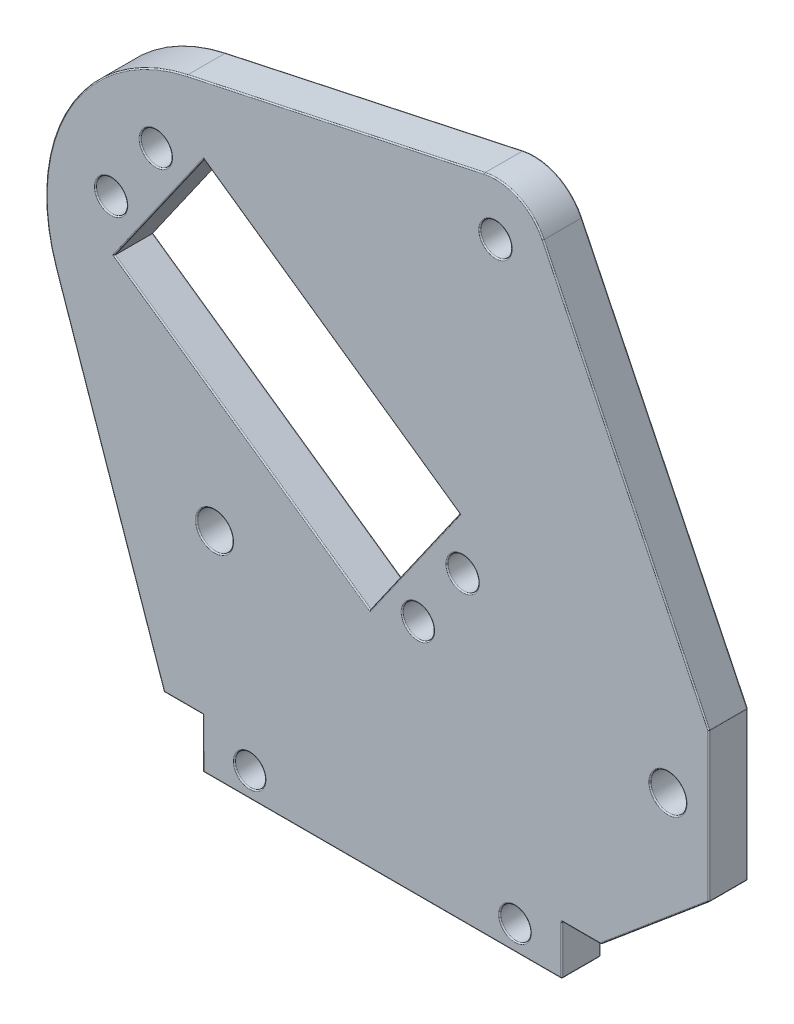
from build123d import *

# Parameters (mm, degrees)
SKETCH2_R           = 2
SKETCH2_R_2         = 2.3
SKETCH2_R_3         = 1.95
BOSS_EXTRUDE2_DEPTH = 5
SKETCH4_W           = 46
SKETCH4_H           = 3.65
CUT_EXTRUDE1_DEPTH  = 6
FILLET1_R           = 0.15


with BuildPart() as part:
    # Sketch2 → Boss-Extrude2 (new body)
    with BuildSketch(Plane.XY):
        with BuildLine():
            Line((-23, 0), (-23, 10))
            Line((-23, 10), (-28, 10))
            Line((-28, 10), (-41.843761624, 50.118193368))
            ThreePointArc((-41.843761624, 50.118193368), (-40.146654928, 68.813612437), (-25.029728066, 79.943634341))
            Line((-25.029728066, 79.943634341), (13.072325527, 88.138211024))
            ThreePointArc((13.072325527, 88.138211024), (17.477220077, 87.602479874), (20.610605748, 84.460506273))
            Line((20.610605748, 84.460506273), (41.85, 40.621529892))
            Line((41.85, 40.621529892), (41.85, 21.621529892))
            Line((41.85, 21.621529892), (28, 10))
            Line((28, 10), (23, 10))
            Line((23, 10), (23, 0))
            Line((23, 0), (-23, 0))
        make_face()
        with Locations((-29.025034449, 69.849224439)):
            Circle(SKETCH2_R, mode=Mode.SUBTRACT)
        with Locations((-34.760798813, 61.657703997)):
            Circle(SKETCH2_R, mode=Mode.SUBTRACT)
        with Locations((10.294263677, 42.317555495)):
            Circle(SKETCH2_R, mode=Mode.SUBTRACT)
        with Locations((4.558499313, 34.126035052)):
            Circle(SKETCH2_R, mode=Mode.SUBTRACT)
        with Locations((14.5, 81.5)):
            Circle(SKETCH2_R, mode=Mode.SUBTRACT)
        with Locations((36.6, 31.121529892)):
            Circle(SKETCH2_R_2, mode=Mode.SUBTRACT)
        with Locations((17, 6.8)):
            Circle(SKETCH2_R_3, mode=Mode.SUBTRACT)
        with Locations((-17, 6.8)):
            Circle(SKETCH2_R_3, mode=Mode.SUBTRACT)
        with Locations((-21.5, 31.121529892)):
            Circle(SKETCH2_R_2, mode=Mode.SUBTRACT)
        Polygon((-22.88054409, 71.650678915), (-34.352072817, 55.26763803), (-1.585991046, 32.324580576), (9.885537681, 48.707621461), align=None, mode=Mode.SUBTRACT)
    extrude(amount=-BOSS_EXTRUDE2_DEPTH)

    # Sketch4 → Cut-Extrude1 (cut, through all)
    with BuildSketch(Plane.XY):
        with Locations((0, 1.825)):
            Rectangle(SKETCH4_W, SKETCH4_H)
    extrude(amount=-CUT_EXTRUDE1_DEPTH, mode=Mode.SUBTRACT)

    # Fillet1
    fillet1_edges = [part.edges().sort_by_distance(p)[0] for p in [
        (-23, 6.825, 0),
        (-25.5, 10, 0),
        (25.5, 10, -5),
        (-34.921880812, 30.059096684, 0),
        (-40.146654928, 68.813612437, 0),
        (-5.978701269, 84.040922682, 0),
        (17.477220077, 87.602479874, 0),
        (31.230302874, 62.541018083, 0),
        (41.85, 31.121529892, 0),
        (34.925, 15.810764946, 0),
        (25.5, 10, 0),
        (34.925, 15.810764946, -5),
        (-28, 10, -2.5),
        (41.85, 31.121529892, -5),
        (41.85, 40.621529892, -2.5),
        (41.85, 21.621529892, -2.5),
        (28, 10, -2.5),
        (23, 10, -2.5),
        (31.230302874, 62.541018083, -5),
        (17.477220077, 87.602479874, -5),
        (-5.978701269, 84.040922682, -5),
        (-6.497503205, 60.179150188, -5),
        (4.149773318, 40.516101019, -5),
        (-17.969031932, 43.796109303, -5),
        (-28.616308454, 63.459158473, -5),
        (-6.497503205, 60.179150188, 0),
        (-28.616308454, 63.459158473, 0),
        (-17.969031932, 43.796109303, 0),
        (4.149773318, 40.516101019, 0),
        (-40.146654928, 68.813612437, -5),
        (-34.921880812, 30.059096684, -5),
        (-31.025034449, 69.849224439, -5),
        (-31.025034449, 69.849224439, 0),
        (-25.5, 10, -5),
        (-36.760798813, 61.657703997, -5),
        (-36.760798813, 61.657703997, 0),
        (-23, 6.825, -5),
        (8.294263677, 42.317555495, -5),
        (8.294263677, 42.317555495, 0),
        (2.558499313, 34.126035052, -5),
        (2.558499313, 34.126035052, 0),
        (12.5, 81.5, -5),
        (12.5, 81.5, 0),
        (34.3, 31.121529892, -5),
        (34.3, 31.121529892, 0),
        (15.05, 6.8, -5),
        (15.05, 6.8, 0),
        (-18.95, 6.8, -5),
        (-18.95, 6.8, 0),
        (-23.8, 31.121529892, -5),
        (-23.8, 31.121529892, 0),
        (23, 6.825, 0),
        (23, 6.825, -5),
        (0, 3.65, -5),
        (-23, 3.65, -2.5),
        (23, 3.65, -2.5),
        (0, 3.65, 0),
    ]]
    fillet(fillet1_edges, radius=FILLET1_R)


solid = part.part
